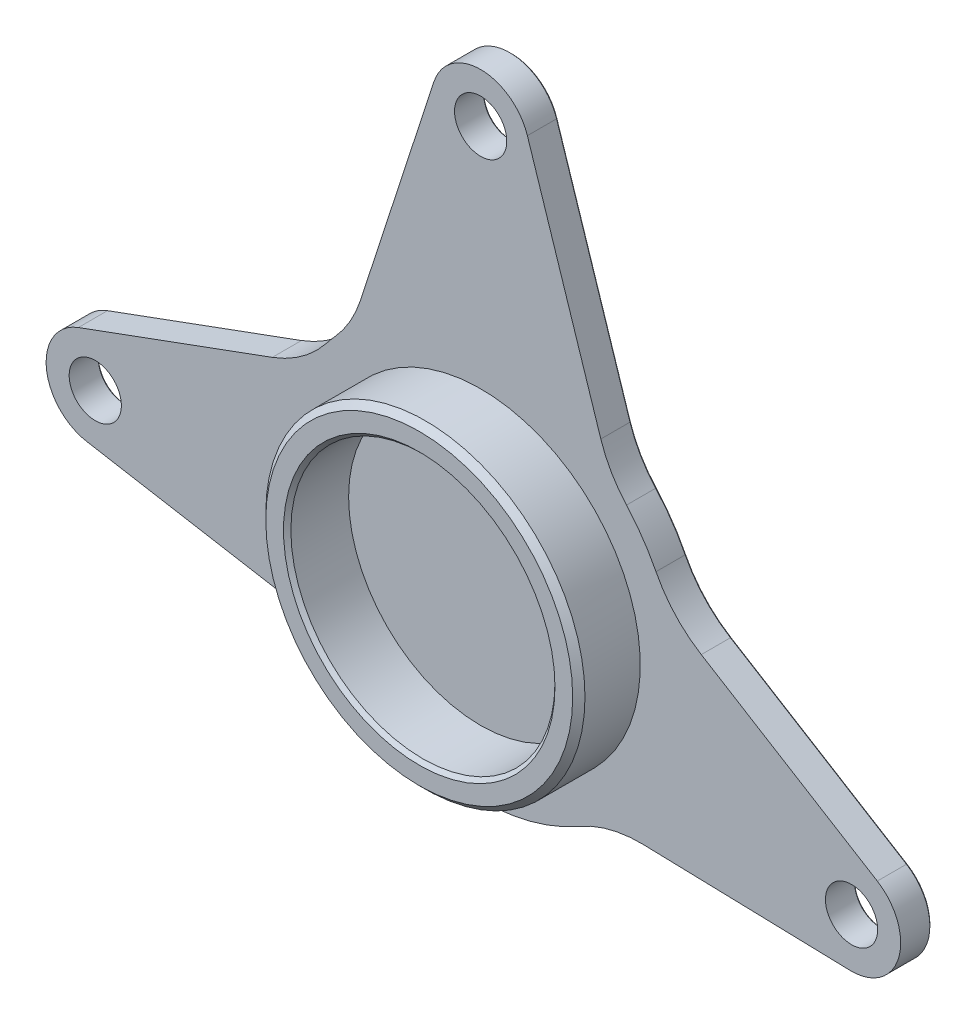
from build123d import *

# Parameters (mm, degrees)
ESQUISSE1_R        = 25.985
ESQUISSE1_R_2      = 21.5
BOSS_EXTRU_1_DEPTH = 10
CHANFREIN1_SIZE    = 1
CHANFREIN2_SIZE    = 0.6
ESQUISSE2_R        = 4.25
BOSS_EXTRU_2_DEPTH = 5
CHANFREIN3_SIZE    = 0.25


with BuildPart() as part:
    # Esquisse1 → Boss.-Extru.1 (new body)
    with BuildSketch(Plane.XY):
        Circle(ESQUISSE1_R)
        Circle(ESQUISSE1_R_2, mode=Mode.SUBTRACT)
    extrude(amount=BOSS_EXTRU_1_DEPTH)

    # Chanfrein1
    chanfrein1_edges = [part.edges().sort_by_distance(p)[0] for p in [
        (-25.985, 0, 10),
    ]]
    chamfer(chanfrein1_edges, length=CHANFREIN1_SIZE)

    # Chanfrein2
    chanfrein2_edges = [part.edges().sort_by_distance(p)[0] for p in [
        (-21.5, 0, 10),
    ]]
    chamfer(chanfrein2_edges, length=CHANFREIN2_SIZE)

    # Esquisse2 → Boss.-Extru.2 (add)
    with BuildSketch(Plane(origin=(0, 0, 0), x_dir=(-1, 0, 0), z_dir=(0, 0, -1))):
        with BuildLine():
            Line((7.60845213, 65.472135955), (19.562751949, 28.680584205))
            ThreePointArc((19.562751949, 28.680584205), (21.2719439, 24.846095602), (23.743927554, 21.452876365))
            ThreePointArc((23.743927554, 21.452876365), (24.442816498, 20.653055987), (25.114776372, 19.830481783))
            ThreePointArc((25.114776372, 19.830481783), (29.077787425, 16.028245766), (33.925593306, 13.447309217))
            Line((33.925593306, 13.447309217), (65.50114543, 1.86803233))
            ThreePointArc((65.50114543, 1.86803233), (70.71462295, -6.359410431), (64.116870777, -13.524661891))
            Line((64.116870777, -13.524661891), (30.982002055, -19.284490011))
            ThreePointArc((30.982002055, -19.284490011), (25.751494228, -20.959077483), (21.173682289, -23.993231927))
            ThreePointArc((21.173682289, -23.993231927), (3.185198765, -31.841082093), (-16.001386984, -27.712012099))
            ThreePointArc((-16.001386984, -27.712012099), (-21.089512057, -25.644782414), (-26.548088017, -25.039469423))
            Line((-26.548088017, -25.039469423), (-60.167318575, -25.957337556))
            ThreePointArc((-60.167318575, -25.957337556), (-68.053671575, -20.240992693), (-64.573244793, -11.143861737))
            Line((-64.573244793, -11.143861737), (-35.917071141, 6.460650663))
            ThreePointArc((-35.917071141, 6.460650663), (-31.676574653, 9.950728723), (-28.545263087, 14.462639983))
            ThreePointArc((-28.545263087, 14.462639983), (-26.377181723, 18.117513195), (-23.743927554, 21.452876365))
            ThreePointArc((-23.743927554, 21.452876365), (-21.2719439, 24.846095602), (-19.562751949, 28.680584205))
            Line((-19.562751949, 28.680584205), (-7.60845213, 65.472135955))
            ThreePointArc((-7.60845213, 65.472135955), (0, 71), (7.60845213, 65.472135955))
        make_face()
        with Locations((0, 63)):
            Circle(ESQUISSE2_R, mode=Mode.SUBTRACT)
        with Locations((62.746778111, -5.642857143)):
            Circle(ESQUISSE2_R, mode=Mode.SUBTRACT)
        with Locations((-60.385652242, -17.96031746)):
            Circle(ESQUISSE2_R, mode=Mode.SUBTRACT)
    extrude(amount=BOSS_EXTRU_2_DEPTH)

    # Chanfrein3
    chanfrein3_edges = [part.edges().sort_by_distance(p)[0] for p in [
        (-25.751494228, -20.959077483, -5),
        (-47.549436416, -16.404575951, -5),
        (-70.71462295, -6.359410431, -5),
        (-49.713369368, 7.657670773, -5),
        (-29.077787425, 16.028245766, -5),
        (-24.442816498, 20.653055987, -5),
        (-21.2719439, 24.846095602, -5),
        (-13.58560204, 47.07636008, -5),
        (0, 71, -5),
        (13.58560204, 47.07636008, -5),
        (21.2719439, 24.846095602, -5),
        (26.377181723, 18.117513195, -5),
        (31.676574653, 9.950728723, -5),
        (50.245157967, -2.341605537, -5),
        (68.053671575, -20.240992693, -5),
        (43.357703296, -25.498403489, -5),
        (21.089512057, -25.644782414, -5),
        (-3.185198765, -31.841082093, -5),
        (4.25, 63, -5),
        (-58.496778111, -5.642857143, -5),
        (64.635652242, -17.96031746, -5),
    ]]
    chamfer(chanfrein3_edges, length=CHANFREIN3_SIZE)


solid = part.part
